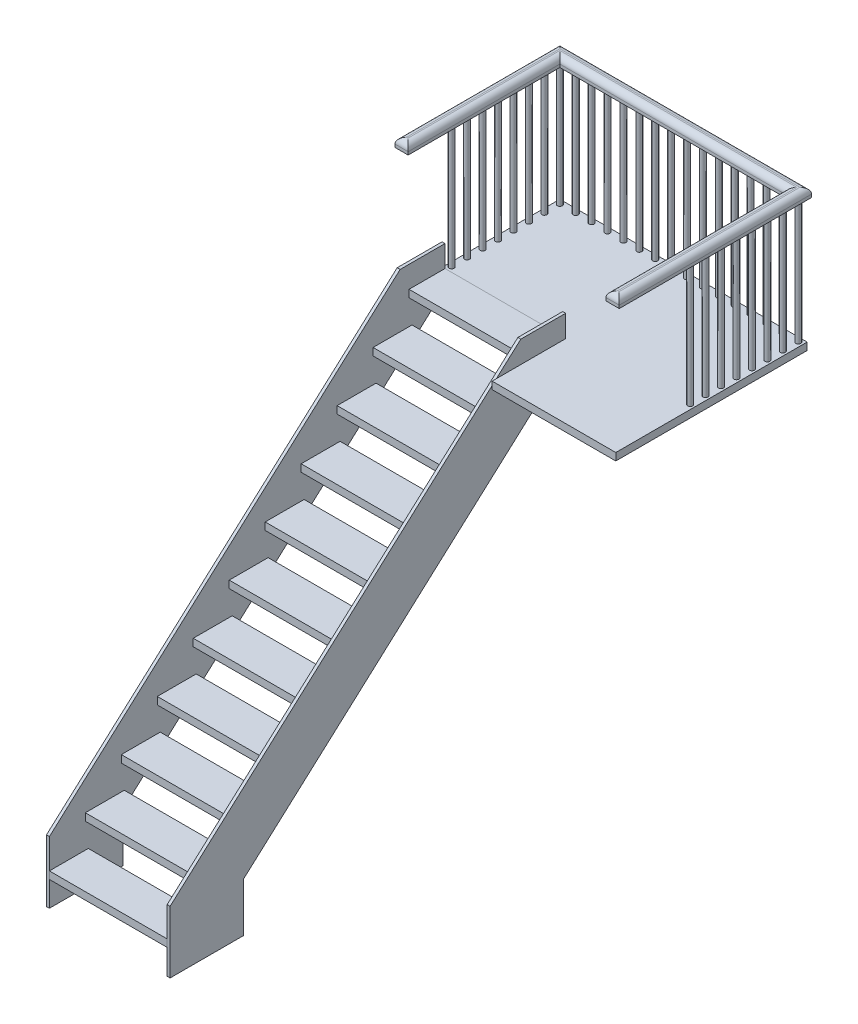
from build123d import *

# Parameters (mm, degrees)
STAIRS_DEPTH         = 800
STAIRS_2_DEPTH       = 800
STAIRS_3_DEPTH       = 800
STAIRS_4_DEPTH       = 800
STAIRS_5_DEPTH       = 800
STAIRS_6_DEPTH       = 800
STAIRS_7_DEPTH       = 800
STAIRS_8_DEPTH       = 800
STAIRS_9_DEPTH       = 800
STAIRS_10_DEPTH      = 800
STAIRS_11_DEPTH      = 800
RIGHT_STRINGER_DEPTH = 20
LEFT_STRINGER_DEPTH  = 20
SKETCH5_W            = 840
SKETCH5_H            = 50
BOSS_EXTRUDE6_DEPTH  = 800
SKETCH6_W            = 800
SKETCH6_H            = 50
BOSS_EXTRUDE7_DEPTH  = 840
SKETCH7_W            = 840
SKETCH7_H            = 50
BOSS_EXTRUDE8_DEPTH  = 500
SKETCH8_R            = 17
BOSS_EXTRUDE9_DEPTH  = 850
BOSS_EXTRUDE11_DEPTH = 60
FILLET1_R            = 40


with BuildPart() as part:
    # Sketch2 → Stairs (new body)
    with BuildSketch(Plane(origin=(0, 0, 0), x_dir=(0, 0, -1), z_dir=(1, 0, 0))):
        Polygon((-9495.73700179, 220), (-9495.73700179, 170), (-9475.73700179, 170), (-9475.73700179, 200), (-9231.402248527, 200), (-9231.402248527, 220), align=None)
    extrude(amount=STAIRS_DEPTH)


with BuildPart() as body_2:
    # Sketch2 → Stairs 2 (new body)
    with BuildSketch(Plane(origin=(0, 0, 0), x_dir=(0, 0, -1), z_dir=(1, 0, 0))):
        Polygon((-9251.402248527, 440), (-9251.402248527, 390), (-9231.402248527, 390), (-9231.402248527, 420), (-8987.067495265, 420), (-8987.067495265, 440), align=None)
    extrude(amount=STAIRS_2_DEPTH)

    # Sketch3 → Right Stringer (add)
    with BuildSketch(Plane(origin=(800, 0, 0), x_dir=(0, 0, -1), z_dir=(1, 0, 0))):
        Polygon((-9495.73700179, 421.844909441), (-7113.01010528, 2567.261843515), (-6808.054715903, 2567.261843515), (-6808.054715903, 2303.591817598), (-8995.73700179, 333.793839747), (-8995.73700179, 0), (-9366.452617586, 0), (-9495.73700179, 0), align=None)
    extrude(amount=RIGHT_STRINGER_DEPTH)

    # Sketch4 → Left Stringer (add)
    with BuildSketch(Plane.ZY):
        Polygon((8995.73700179, 333.793839747), (6808.054715903, 2303.591817598), (6808.054715903, 2567.261843515), (7113.01010528, 2567.261843515), (9495.73700179, 421.844909441), (9495.73700179, 333.793839747), (9495.73700179, 0), (8995.73700179, 0), align=None)
    extrude(amount=LEFT_STRINGER_DEPTH)



with BuildPart() as body_3:
    # Sketch2 → Stairs 3 (new body)
    with BuildSketch(Plane(origin=(0, 0, 0), x_dir=(0, 0, -1), z_dir=(1, 0, 0))):
        Polygon((-9007.067495265, 660), (-9007.067495265, 610), (-8987.067495265, 610), (-8987.067495265, 640), (-8742.732742002, 640), (-8742.732742002, 660), align=None)
    extrude(amount=STAIRS_3_DEPTH)


with BuildPart() as body_4:
    # Sketch2 → Stairs 4 (new body)
    with BuildSketch(Plane(origin=(0, 0, 0), x_dir=(0, 0, -1), z_dir=(1, 0, 0))):
        Polygon((-8762.732742002, 880), (-8762.732742002, 830), (-8742.732742002, 830), (-8742.732742002, 860), (-8498.39798874, 860), (-8498.39798874, 880), align=None)
    extrude(amount=STAIRS_4_DEPTH)


with BuildPart() as body_5:
    # Sketch2 → Stairs 5 (new body)
    with BuildSketch(Plane(origin=(0, 0, 0), x_dir=(0, 0, -1), z_dir=(1, 0, 0))):
        Polygon((-8518.39798874, 1100), (-8518.39798874, 1050), (-8498.39798874, 1050), (-8498.39798874, 1080), (-8254.063235477, 1080), (-8254.063235477, 1100), align=None)
    extrude(amount=STAIRS_5_DEPTH)


with BuildPart() as body_6:
    # Sketch2 → Stairs 6 (new body)
    with BuildSketch(Plane(origin=(0, 0, 0), x_dir=(0, 0, -1), z_dir=(1, 0, 0))):
        Polygon((-8274.063235477, 1320), (-8274.063235477, 1270), (-8254.063235477, 1270), (-8254.063235477, 1300), (-8009.728482215, 1300), (-8009.728482215, 1320), align=None)
    extrude(amount=STAIRS_6_DEPTH)


with BuildPart() as body_7:
    # Sketch2 → Stairs 7 (new body)
    with BuildSketch(Plane(origin=(0, 0, 0), x_dir=(0, 0, -1), z_dir=(1, 0, 0))):
        Polygon((-8029.728482215, 1540), (-8029.728482215, 1490), (-8009.728482215, 1490), (-8009.728482215, 1520), (-7765.393728953, 1520), (-7765.393728953, 1540), align=None)
    extrude(amount=STAIRS_7_DEPTH)


with BuildPart() as body_8:
    # Sketch2 → Stairs 8 (new body)
    with BuildSketch(Plane(origin=(0, 0, 0), x_dir=(0, 0, -1), z_dir=(1, 0, 0))):
        Polygon((-7785.393728953, 1760), (-7785.393728953, 1710), (-7765.393728953, 1710), (-7765.393728953, 1740), (-7521.05897569, 1740), (-7521.05897569, 1760), align=None)
    extrude(amount=STAIRS_8_DEPTH)


with BuildPart() as body_9:
    # Sketch2 → Stairs 9 (new body)
    with BuildSketch(Plane(origin=(0, 0, 0), x_dir=(0, 0, -1), z_dir=(1, 0, 0))):
        Polygon((-7541.05897569, 1980), (-7541.05897569, 1930), (-7521.05897569, 1930), (-7521.05897569, 1960), (-7276.724222428, 1960), (-7276.724222428, 1980), align=None)
    extrude(amount=STAIRS_9_DEPTH)


with BuildPart() as body_10:
    # Sketch2 → Stairs 10 (new body)
    with BuildSketch(Plane(origin=(0, 0, 0), x_dir=(0, 0, -1), z_dir=(1, 0, 0))):
        Polygon((-7296.724222428, 2200), (-7296.724222428, 2150), (-7276.724222428, 2150), (-7276.724222428, 2180), (-7032.389469165, 2180), (-7032.389469165, 2200), align=None)
    extrude(amount=STAIRS_10_DEPTH)


with BuildPart() as body_11:
    # Sketch2 → Stairs 11 (new body)
    with BuildSketch(Plane(origin=(0, 0, 0), x_dir=(0, 0, -1), z_dir=(1, 0, 0))):
        Polygon((-7052.389469165, 2420), (-7052.389469165, 2370), (-7032.389469165, 2370), (-7032.389469165, 2400), (-6808.054715903, 2400), (-6808.054715903, 2420), align=None)
    extrude(amount=STAIRS_11_DEPTH)


with BuildPart() as body_2_1:
    add(body_2.part)

    add(body_11.part)  # Boss-Extrude6 merges body 11
    # Sketch5 → Boss-Extrude6 (add)
    with BuildSketch(Plane(origin=(0, 0, 6808.054715903), x_dir=(-1, 0, 0), z_dir=(0, 0, -1))):
        with Locations((-400, 2392.628302845)):
            Rectangle(SKETCH5_W, SKETCH5_H)
    extrude(amount=BOSS_EXTRUDE6_DEPTH)

    # Sketch6 → Boss-Extrude7 (add)
    with BuildSketch(Plane(origin=(820, 0, 0), x_dir=(0, 0, -1), z_dir=(1, 0, 0))):
        with Locations((-6408.054715903, 2392.628302845)):
            Rectangle(SKETCH6_W, SKETCH6_H)
    extrude(amount=BOSS_EXTRUDE7_DEPTH)

    # Sketch7 → Boss-Extrude8 (add)
    with BuildSketch(Plane.XY.offset(6808.054715903)):
        with Locations((1240, 2392.628302845)):
            Rectangle(SKETCH7_W, SKETCH7_H)
    extrude(amount=BOSS_EXTRUDE8_DEPTH)

    # Sketch8 → Boss-Extrude9 (add)
    with BuildSketch(Plane(origin=(0, 2417.628302845, 0), x_dir=(1, 0, 0), z_dir=(0, 1, 0))):
        with Locations((10, -6038.054715903)):
            Circle(SKETCH8_R)
        with Locations((10, -6143.054715903)):
            Circle(SKETCH8_R)
        with Locations((10, -6248.054715903)):
            Circle(SKETCH8_R)
        with Locations((10, -6353.054715903)):
            Circle(SKETCH8_R)
        with Locations((10, -6458.054715903)):
            Circle(SKETCH8_R)
        with Locations((10, -6563.054715903)):
            Circle(SKETCH8_R)
        with Locations((10, -6668.054715903)):
            Circle(SKETCH8_R)
        with Locations((10, -6773.054715903)):
            Circle(SKETCH8_R)
        with Locations((118, -6038.054715903)):
            Circle(SKETCH8_R)
        with Locations((226, -6038.054715903)):
            Circle(SKETCH8_R)
        with Locations((334, -6038.054715903)):
            Circle(SKETCH8_R)
        with Locations((442, -6038.054715903)):
            Circle(SKETCH8_R)
        with Locations((550, -6038.054715903)):
            Circle(SKETCH8_R)
        with Locations((658, -6038.054715903)):
            Circle(SKETCH8_R)
        with Locations((766, -6038.054715903)):
            Circle(SKETCH8_R)
        with Locations((874, -6038.054715903)):
            Circle(SKETCH8_R)
        with Locations((982, -6038.054715903)):
            Circle(SKETCH8_R)
        with Locations((1090, -6038.054715903)):
            Circle(SKETCH8_R)
        with Locations((1198, -6038.054715903)):
            Circle(SKETCH8_R)
        with Locations((1306, -6038.054715903)):
            Circle(SKETCH8_R)
        with Locations((1414, -6038.054715903)):
            Circle(SKETCH8_R)
        with Locations((1522, -6038.054715903)):
            Circle(SKETCH8_R)
        with Locations((1630, -6038.054715903)):
            Circle(SKETCH8_R)
        with Locations((1630, -6143.054715903)):
            Circle(SKETCH8_R)
        with Locations((1630, -6248.054715903)):
            Circle(SKETCH8_R)
        with Locations((1630, -6353.054715903)):
            Circle(SKETCH8_R)
        with Locations((1630, -6458.054715903)):
            Circle(SKETCH8_R)
        with Locations((1630, -6563.054715903)):
            Circle(SKETCH8_R)
        with Locations((1630, -6668.054715903)):
            Circle(SKETCH8_R)
        with Locations((1630, -6773.054715903)):
            Circle(SKETCH8_R)
    extrude(amount=BOSS_EXTRUDE9_DEPTH)

    # Sketch9 → Boss-Extrude11 (add)
    with BuildSketch(Plane(origin=(0, 3267.628302845, 0), x_dir=(1, 0, 0), z_dir=(0, 1, 0))):
        Polygon((-35, -5993.054715903), (55, -5993.054715903), (1675, -5993.054715903), (1675, -6083.054715903), (1675, -7299.514103461), (1585, -7299.514103461), (1585, -6083.054715903), (55, -6083.054715903), (55, -7113.36779525), (-35, -7113.36779525), align=None)
    extrude(amount=BOSS_EXTRUDE11_DEPTH)

    # Fillet1
    fillet1_edges = [body_2_1.edges().sort_by_distance(p)[0] for p in [
        (820, 3327.628302845, 5993.054715903),
        (1675, 3327.628302845, 6646.284409682),
        (1630, 3327.628302845, 7299.514103461),
        (1585, 3327.628302845, 6691.284409682),
        (820, 3327.628302845, 6083.054715903),
        (55, 3327.628302845, 6598.211255576),
        (10, 3327.628302845, 7113.36779525),
        (-35, 3327.628302845, 6553.211255576),
    ]]
    fillet(fillet1_edges, radius=FILLET1_R)


solid = Compound([part.part, body_3.part, body_4.part, body_5.part, body_6.part, body_7.part, body_8.part, body_9.part, body_10.part, body_2_1.part])
